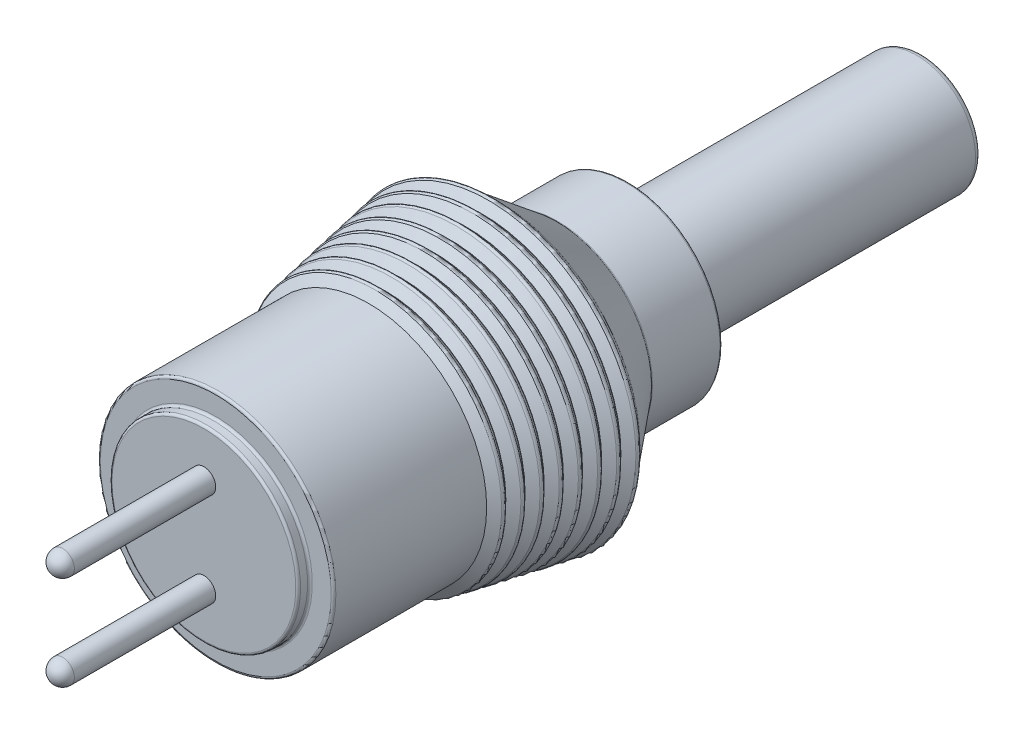
from build123d import *

# Parameters (mm, degrees)
SKETCH2_R           = 1.75
CUT_EXTRUDE1_DEPTH  = 12
FILLET1_R           = 0.1
FILLET2_R           = 0.25
FILLET3_R           = 0.1
SKETCH3_R           = 0.5
BOSS_EXTRUDE1_DEPTH = 6.5
FILLET4_R           = 0.5


with BuildPart() as part:
    # Sketch1 → Revolve1 (revolve)
    with BuildSketch(Plane(origin=(0, 0, 0), x_dir=(0, 0, -1), z_dir=(1, 0, 0))):
        Polygon((-15.25, 0), (15.25, 0), (15.25, 2.5), (2.75, 2.5), (2.75, 4), (-0.25, 4), (-2.75, 6), (-2.752154412, 5.999608289), (-3.101223072, 6.355057367), (-3.428634063, 5.876611989), (-3.440823791, 5.874395674), (-3.789942599, 6.229895816), (-4.117400625, 5.751381704), (-4.12949317, 5.74918306), (-4.478662125, 6.104734266), (-4.806402367, 5.625807753), (-4.817961961, 5.62376619), (-5.167381652, 5.979572715), (-5.49493375, 5.500921136), (-5.506831929, 5.498757831), (-5.856101178, 5.854411165), (-6.183700313, 5.375690852), (-6.195501308, 5.373545217), (-6.544820705, 5.729249614), (-6.872466875, 5.250460568), (-6.884170687, 5.248332602), (-7.233540232, 5.604088063), (-7.561233438, 5.125230284), (-7.572840067, 5.123119988), (-7.922259758, 5.478926513), (-8.25, 5), (-14.75, 5), (-14.75, 4), (-15.25, 4), align=None)
    revolve(axis=Axis((0, 0, 15.25), (0, 0, -1)))

    # Sketch2 → Cut-Extrude1 (cut)
    with BuildSketch(Plane(origin=(0, 0, -15.25), x_dir=(-1, 0, 0), z_dir=(0, 0, -1))):
        Circle(SKETCH2_R)
    extrude(amount=-CUT_EXTRUDE1_DEPTH, mode=Mode.SUBTRACT)

    # Fillet1
    fillet1_edges = [part.edges().sort_by_distance(p)[0] for p in [
        (0, -6.355057367, 3.101223072),
        (0, -6.229895816, 3.789942599),
        (0, -6.104734266, 4.478662125),
        (0, -5.979572715, 5.167381652),
        (0, -5.854411165, 5.856101178),
        (0, -5.729249614, 6.544820705),
        (0, -5.604088063, 7.233540232),
        (0, -5.478926513, 7.922259758),
    ]]
    fillet(fillet1_edges, radius=FILLET1_R)

    # Fillet2
    fillet2_edges = [part.edges().sort_by_distance(p)[0] for p in [
        (0, -2.5, -15.25),
    ]]
    fillet(fillet2_edges, radius=FILLET2_R)

    # Fillet3
    fillet3_edges = [part.edges().sort_by_distance(p)[0] for p in [
        (0, -2.5, -2.75),
        (0, -4, -2.75),
        (0, -4, 0.25),
        (0, -5, 14.75),
        (0, -4, 14.75),
        (0, -4, 15.25),
    ]]
    fillet(fillet3_edges, radius=FILLET3_R)

    # Sketch3 → Boss-Extrude1 (add)
    with BuildSketch(Plane.XY.offset(15.25)):
        with Locations((0, 2)):
            Circle(SKETCH3_R)
        with Locations((0, -2)):
            Circle(SKETCH3_R)
    extrude(amount=BOSS_EXTRUDE1_DEPTH)

    # Fillet4
    fillet4_edges = [part.edges().sort_by_distance(p)[0] for p in [
        (-0.5, 2, 21.75),
        (-0.5, -2, 21.75),
    ]]
    fillet(fillet4_edges, radius=FILLET4_R)


solid = part.part
